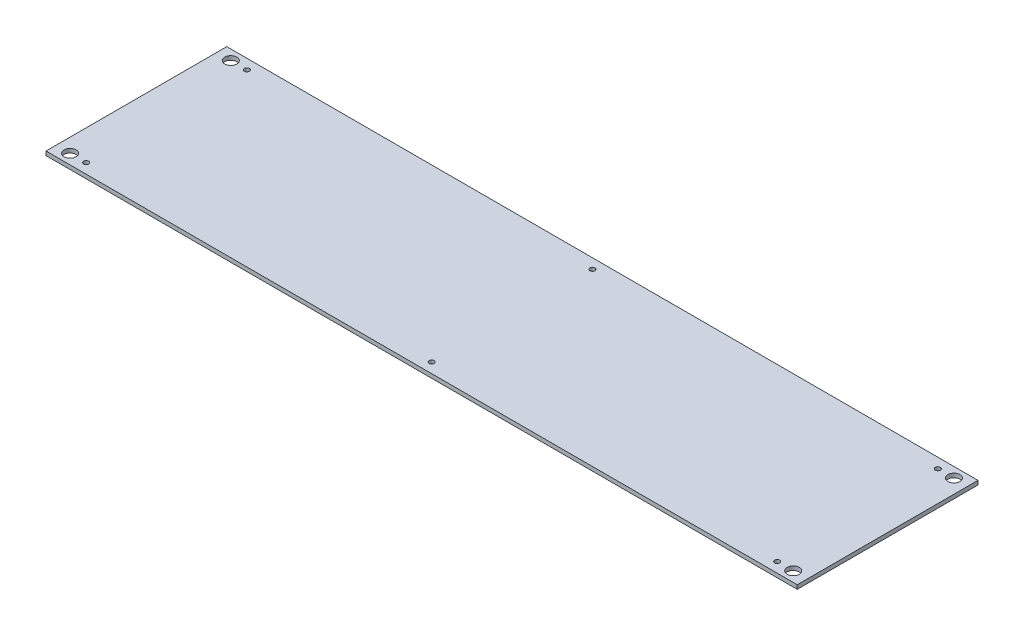
from build123d import *

# Parameters (mm, degrees)
SKETCH1_W           = 748
SKETCH1_H           = 180
SKETCH1_R           = 2.5
SKETCH1_R_2         = 6
BOSS_EXTRUDE1_DEPTH = 4


with BuildPart() as part:
    # Sketch1 → Boss-Extrude1 (new body)
    with BuildSketch(Plane(origin=(0, 0, 0), x_dir=(1, 0, 0), z_dir=(0, 1, 0))):
        Rectangle(SKETCH1_W, SKETCH1_H)
        with Locations((-344, 80)):
            Circle(SKETCH1_R, mode=Mode.SUBTRACT)
        with Locations((0, 80)):
            Circle(SKETCH1_R, mode=Mode.SUBTRACT)
        with Locations((344, 80)):
            Circle(SKETCH1_R, mode=Mode.SUBTRACT)
        with Locations((-344, -80)):
            Circle(SKETCH1_R, mode=Mode.SUBTRACT)
        with Locations((0, -80)):
            Circle(SKETCH1_R, mode=Mode.SUBTRACT)
        with Locations((344, -80)):
            Circle(SKETCH1_R, mode=Mode.SUBTRACT)
        with Locations((-360, 80)):
            Circle(SKETCH1_R_2, mode=Mode.SUBTRACT)
        with Locations((-360, -80)):
            Circle(SKETCH1_R_2, mode=Mode.SUBTRACT)
        with Locations((360, -80)):
            Circle(SKETCH1_R_2, mode=Mode.SUBTRACT)
        with Locations((360, 80)):
            Circle(SKETCH1_R_2, mode=Mode.SUBTRACT)
    extrude(amount=BOSS_EXTRUDE1_DEPTH)


solid = part.part
